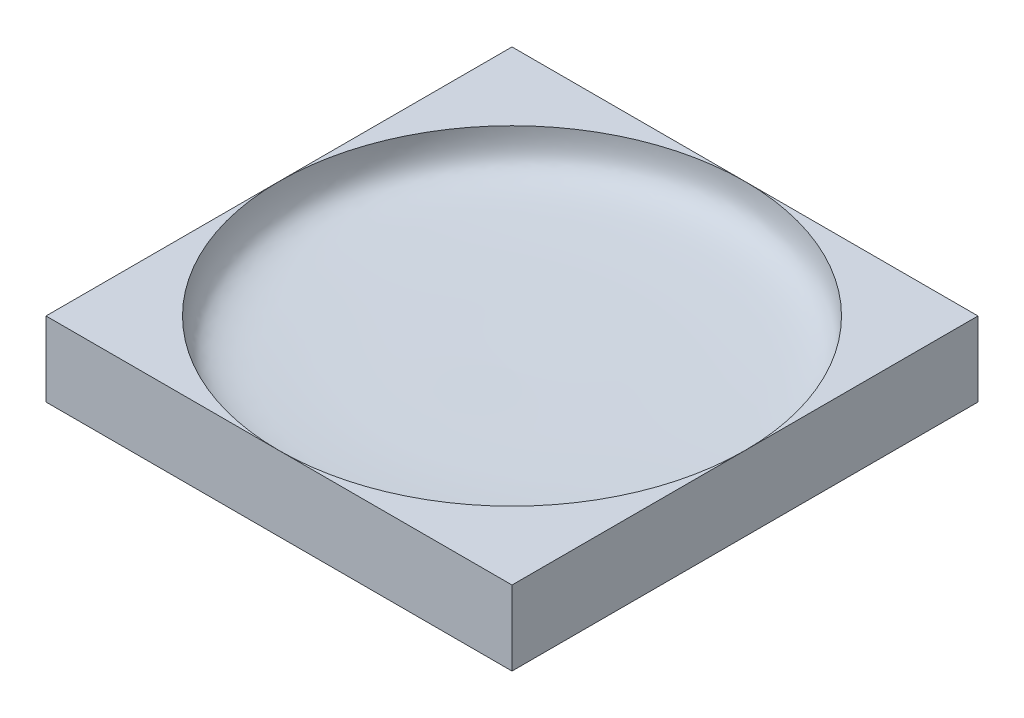
from build123d import *

# Parameters (mm, degrees)
SKETCH1_W           = 250
SKETCH1_H           = 250
BOSS_EXTRUDE1_DEPTH = 40


with BuildPart() as part:
    # Sketch1 → Boss-Extrude1 (new body)
    with BuildSketch(Plane(origin=(0, 0, 0), x_dir=(1, 0, 0), z_dir=(0, 1, 0))):
        Rectangle(SKETCH1_W, SKETCH1_H)
    extrude(amount=BOSS_EXTRUDE1_DEPTH)

    # Sketch2 → Cut-Revolve2 (revolve, cut)
    with BuildSketch(Plane.XY):
        with BuildLine():
            Line((0, 15), (0, 63.116181733))
            Line((0, 63.116181733), (125, 40))
            add(Edge.make_bspline(
                [(0, 15), (48.1962468, 15.882356201), (65.959558565, 14.697330468), (121.032855803, 18.917893375), (125, 29.712177283), (125, 40)],
                knots=[0, 0, 0, 0, 0.694215698, 0.861705648, 1, 1, 1, 1], degree=3))
        make_face()
    revolve(axis=Axis((0, 15, 0), (0, 1, 0)), mode=Mode.SUBTRACT)


solid = part.part
